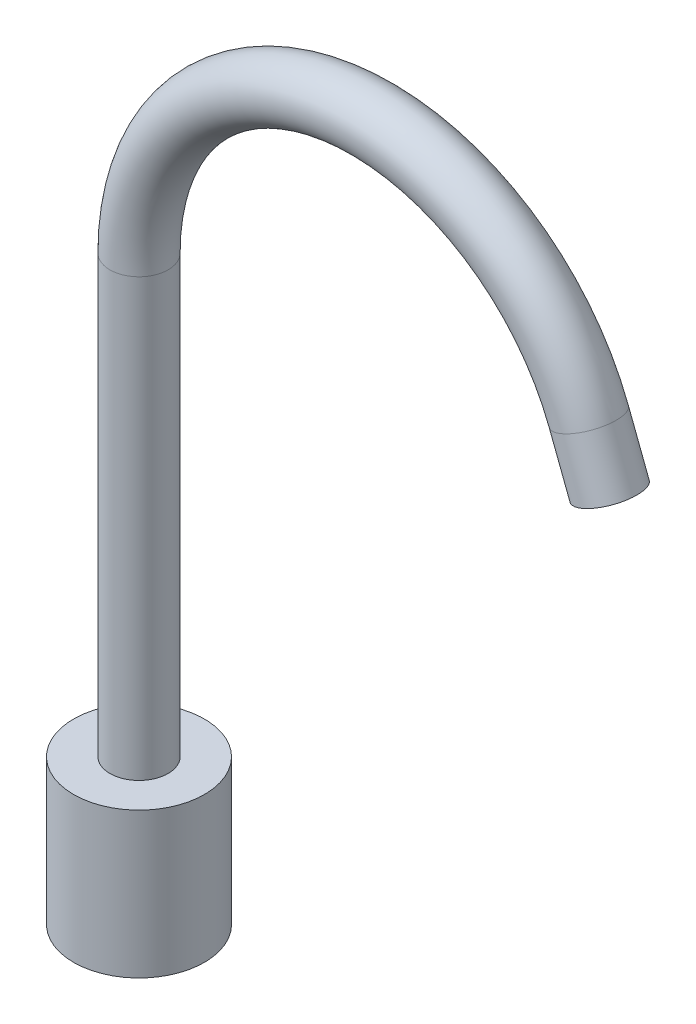
from build123d import *

# Parameters (mm, degrees)
SKETCH_2_R      = 10
SKETCH_3_R      = 22.5
EXTRUDE_1_DEPTH = 50


with BuildPart() as part:
    # По траектории1: sweep along a path in Эскиз1
    with BuildLine(Plane.XY) as sweep_1_path:
        Line((0, 0), (0, 200))
        ThreePointArc((0, 200), (65.444238832, 278.664666889), (154.703245421, 228.62560259))
        Line((154.703245421, 228.62560259), (161.859646068, 209.949791235))
    # Эскиз2 → По траектории1 (sweep)
    with BuildSketch(Plane(origin=(0, 0, 0), x_dir=(1, 0, 0), z_dir=(0, 1, 0))):
        Circle(SKETCH_2_R)
    sweep(path=sweep_1_path.line)

    # Эскиз3 → Бобышка-Вытянуть1 (add)
    with BuildSketch(Plane(origin=(0, 0, 0), x_dir=(1, 0, 0), z_dir=(0, 1, 0))):
        Circle(SKETCH_3_R)
    extrude(amount=EXTRUDE_1_DEPTH)


solid = part.part
